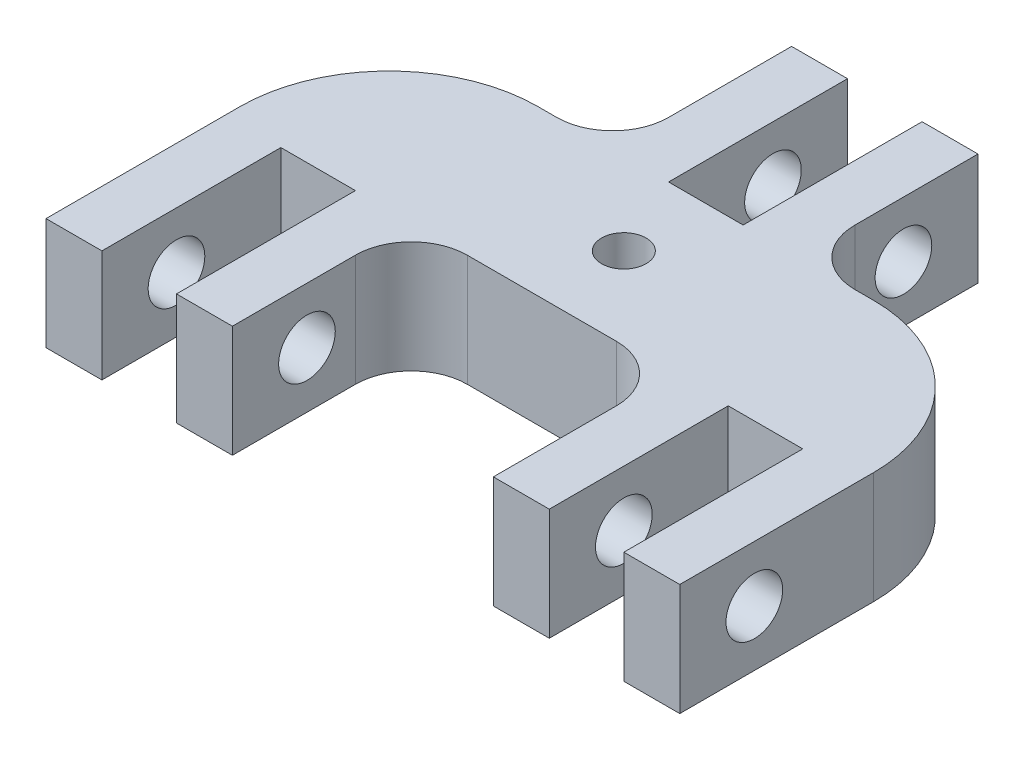
from build123d import *

# Parameters (mm, degrees)
BOSS_EXTRUDE1_DEPTH                   = 9.525
SKETCH2_W                             = 19.05
SKETCH2_H                             = 15.24
SKETCH2_W_2                           = 22.225
CUT_EXTRUDE1_DEPTH                    = 10.525
F_3_16_0_1875_CLEARANCE_DOWEL_HOLE1_D = 4.826
F_10_24_TAPPED_HOLE1_D                = 3.7973
F_10_24_TAPPED_HOLE1_DEPTH            = 9.525
FILLET1_R                             = 4.7625
FILLET2_R                             = 12.7


with BuildPart() as part:
    # Sketch1 → Boss-Extrude1 (new body)
    with BuildSketch(Plane(origin=(0, 0, 0), x_dir=(1, 0, 0), z_dir=(0, 1, 0))):
        Polygon((-3.175, 22.225), (-3.175, 6.985), (3.175, 6.985), (3.175, 22.225), (26.9875, 22.225), (26.9875, -22.225), (22.225, -22.225), (22.225, -6.985), (15.875, -6.985), (15.875, -22.225), (-15.875, -22.225), (-15.875, -6.985), (-22.225, -6.985), (-22.225, -22.225), (-26.9875, -22.225), (-26.9875, 22.225), align=None)
    extrude(amount=BOSS_EXTRUDE1_DEPTH)

    # Sketch2 → Cut-Extrude1 (cut, through all)
    with BuildSketch(Plane(origin=(0, 9.525, 0), x_dir=(1, 0, 0), z_dir=(0, 1, 0))):
        with Locations((-17.4625, 14.605)):
            Rectangle(SKETCH2_W, SKETCH2_H)
        with Locations((17.4625, 14.605)):
            Rectangle(SKETCH2_W, SKETCH2_H)
        with Locations((0, -14.605)):
            Rectangle(SKETCH2_W_2, SKETCH2_H)
    extrude(amount=-CUT_EXTRUDE1_DEPTH, mode=Mode.SUBTRACT)

    # 3/16 (0.1875) Clearance Dowel Hole1 (through all)
    with Locations(Plane(origin=(26.9875, 0, 0), x_dir=(0, 0, -1), z_dir=(1, 0, 0))):
        with Locations((-15.875, 4.7625), (15.875, 4.7625)):
            Hole(F_3_16_0_1875_CLEARANCE_DOWEL_HOLE1_D / 2)

    # #10-24 Tapped Hole1
    with Locations(Plane(origin=(0, 9.525, 0), x_dir=(1, 0, 0), z_dir=(0, 1, 0))):
        with Locations((0, 0)):
            Hole(F_10_24_TAPPED_HOLE1_D / 2, depth=F_10_24_TAPPED_HOLE1_DEPTH)

    # Fillet1
    fillet1_edges = [part.edges().sort_by_distance(p)[0] for p in [
        (-7.9375, 4.7625, -6.985),
        (7.9375, 4.7625, -6.985),
        (-11.1125, 4.7625, 6.985),
        (11.1125, 4.7625, 6.985),
    ]]
    fillet(fillet1_edges, radius=FILLET1_R)

    # Fillet2
    fillet2_edges = [part.edges().sort_by_distance(p)[0] for p in [
        (-26.9875, 4.7625, -6.985),
        (26.9875, 4.7625, -6.985),
    ]]
    fillet(fillet2_edges, radius=FILLET2_R)


solid = part.part
